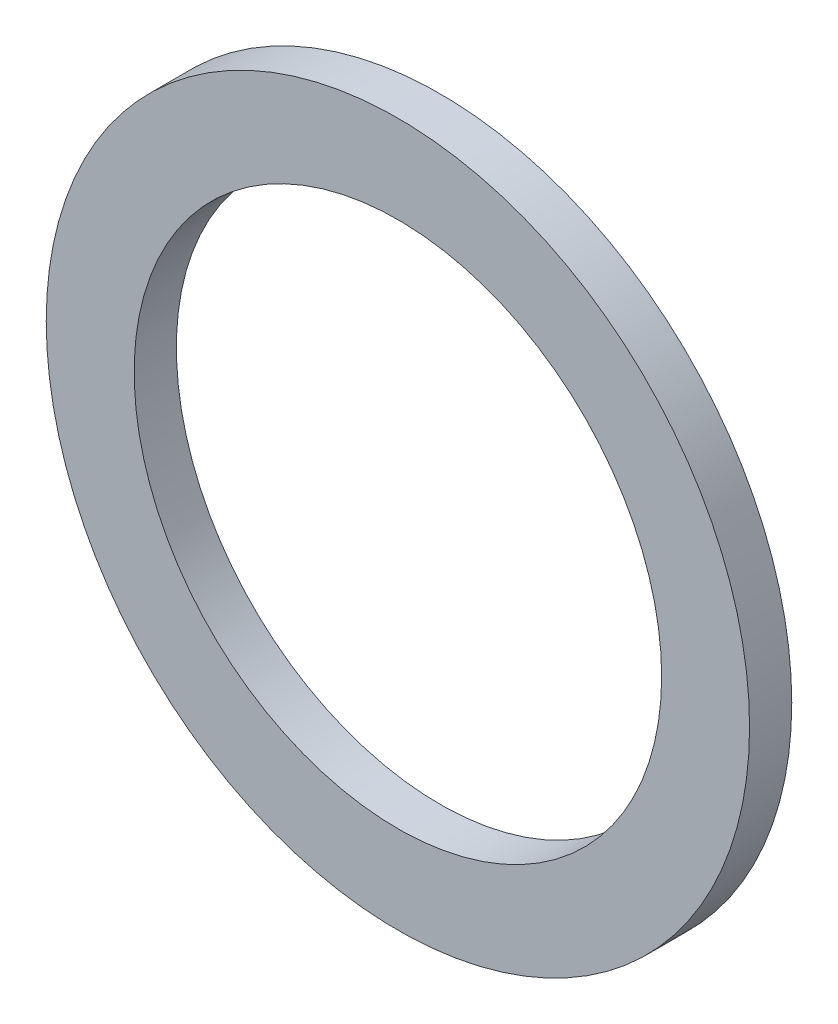
from build123d import *

# Parameters (mm, degrees)
SKETCH1_R           = 10
SKETCH1_R_2         = 7.5
BOSS_EXTRUDE1_DEPTH = 1.2


with BuildPart() as part:
    # Sketch1 → Boss-Extrude1 (new body)
    with BuildSketch(Plane.XY):
        Circle(SKETCH1_R)
        Circle(SKETCH1_R_2, mode=Mode.SUBTRACT)
    extrude(amount=BOSS_EXTRUDE1_DEPTH)


solid = part.part
